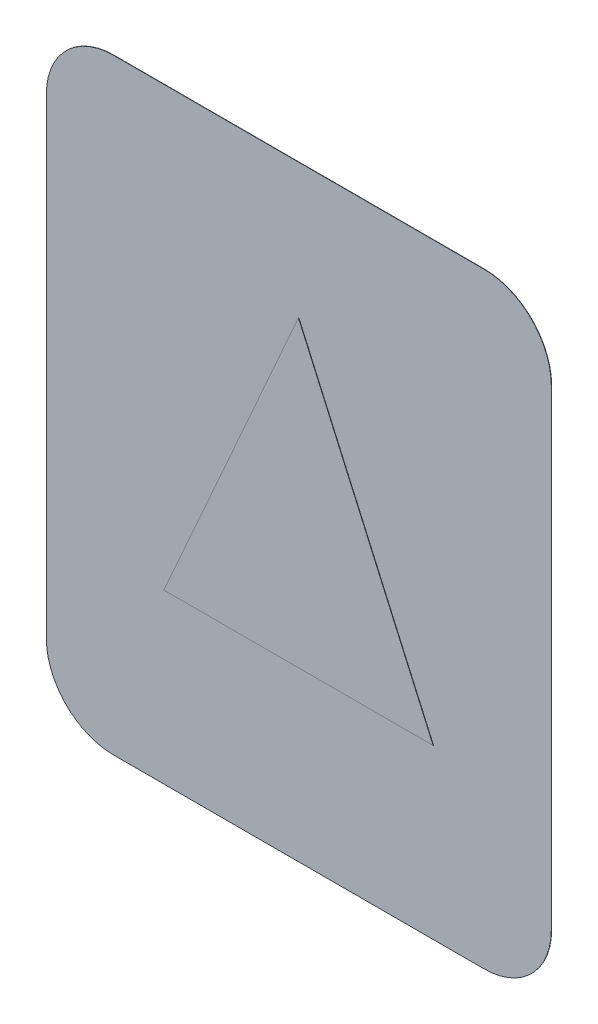
from build123d import *

# Parameters (mm, degrees)
SALIENTE_EXTRUIR2_DEPTH = 0.1
SALIENTE_EXTRUIR3_DEPTH = 0.1


with BuildPart() as part:
    # Croquis1 → Saliente-Extruir2 (new body)
    with BuildSketch(Plane.XY):
        with BuildLine():
            Line((-47.708333333, 74.739583333), (62.291666667, 74.739583333))
            ThreePointArc((62.291666667, 74.739583333), (76.43380229, 68.881718957), (82.291666667, 54.739583333))
            Line((82.291666667, 54.739583333), (82.291666667, -85.260416667))
            ThreePointArc((82.291666667, -85.260416667), (76.43380229, -99.40255229), (62.291666667, -105.260416667))
            Line((62.291666667, -105.260416667), (-47.708333333, -105.260416667))
            ThreePointArc((-47.708333333, -105.260416667), (-61.850468957, -99.40255229), (-67.708333333, -85.260416667))
            Line((-67.708333333, -85.260416667), (-67.708333333, 54.739583333))
            ThreePointArc((-67.708333333, 54.739583333), (-61.850468957, 68.881718957), (-47.708333333, 74.739583333))
        make_face()
    extrude(amount=SALIENTE_EXTRUIR2_DEPTH)

    # Croquis2 → Saliente-Extruir3 (add)
    with BuildSketch(Plane.XY.offset(0.1)):
        Polygon((-32.708333333, -55.260416667), (7.291666667, 34.739583333), (47.291666667, -55.260416667), align=None)
    extrude(amount=SALIENTE_EXTRUIR3_DEPTH)


solid = part.part
